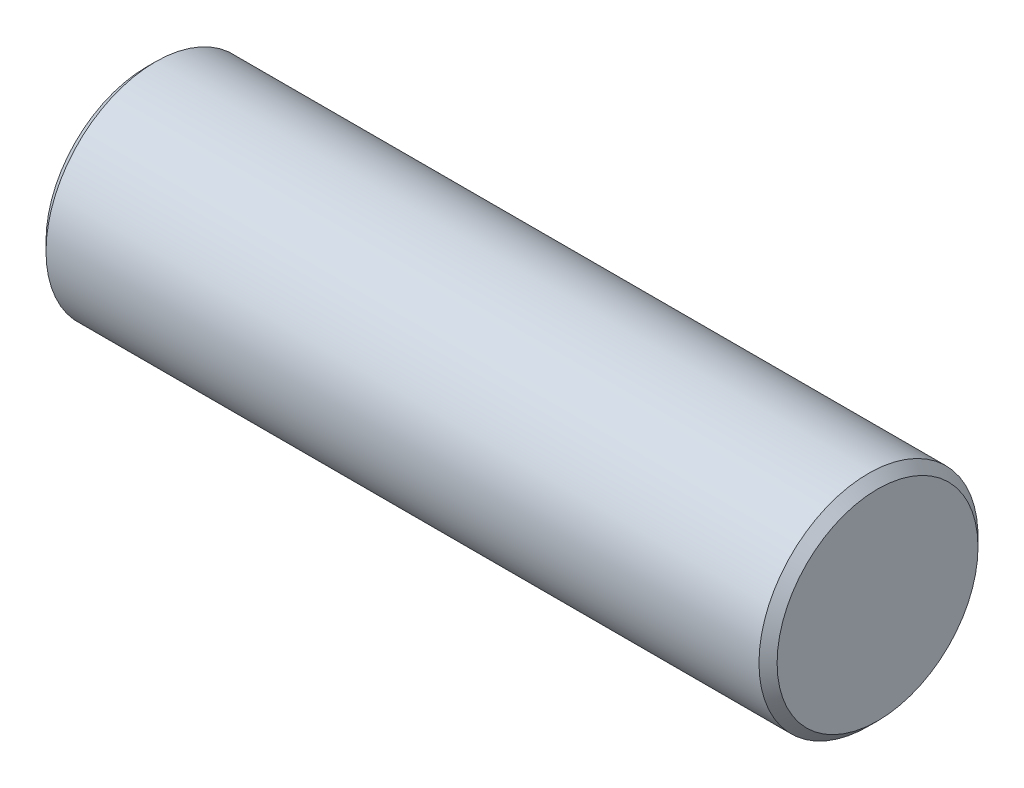
from build123d import *

# Parameters (mm, degrees)
SKETCH2_W     = 5
SKETCH2_H     = 0.749
CHAMFER1_SIZE = 0.062


with BuildPart() as part:
    # Sketch2 → Revolve1 (revolve)
    with BuildSketch(Plane.XY):
        with Locations((0, 0.3745)):
            Rectangle(SKETCH2_W, SKETCH2_H)
    revolve(axis=Axis((-2.312745811, 0, 0), (1, 0, 0)))

    # Chamfer1
    chamfer1_edges = [part.edges().sort_by_distance(p)[0] for p in [
        (-2.5, -0.749, 0),
        (2.5, -0.749, 0),
    ]]
    chamfer(chamfer1_edges, length=CHAMFER1_SIZE)


solid = part.part
